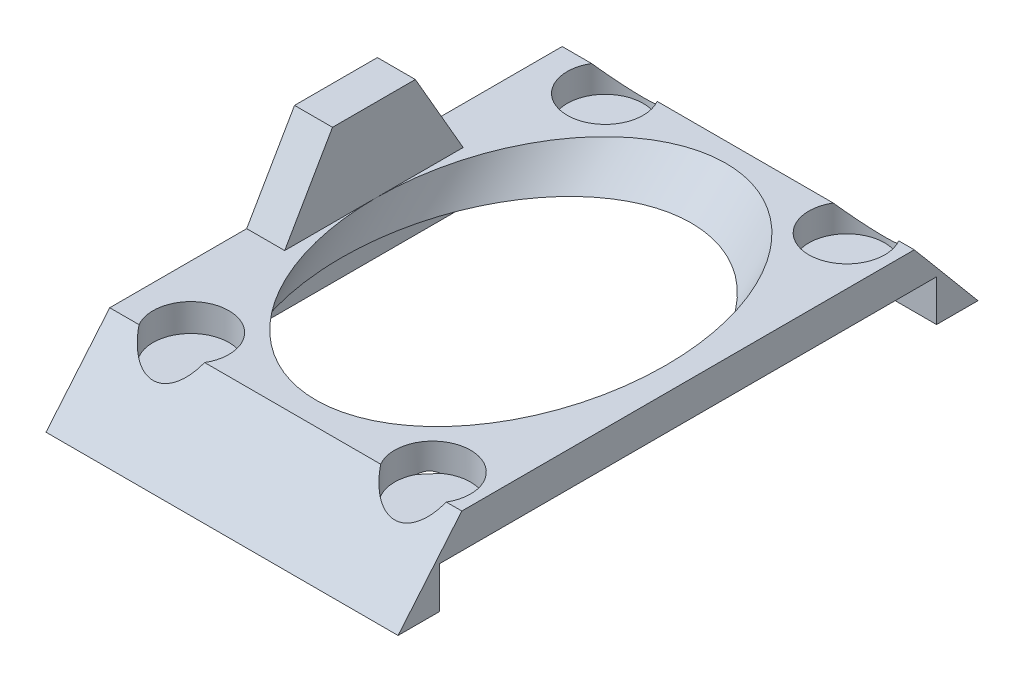
from build123d import *

# Parameters (mm, degrees)
SKETCH1_W                = 25.5
SKETCH1_H                = 42
BOSS_EXTRUDE1_DEPTH      = 5.5
SKETCH2_W                = 25
SKETCH2_H                = 36
CUT_EXTRUDE1_DEPTH       = 3
SKETCH3_R                = 10.5
CUT_EXTRUDE6_DEPTH       = 29
SKETCH6_R                = 2.75
CUT_EXTRUDE7_DEPTH       = 2
CUT_EXTRUDE8_DEPTH       = 13.5
CUT_EXTRUDE8_DEPTH_BACK  = 14
BOSS_EXTRUDE2_DEPTH      = 2.75
SKETCH9_R                = 2.5
CUT_EXTRUDE11_DEPTH      = 2.25
CUT_EXTRUDE12_DEPTH      = 13.5
CUT_EXTRUDE12_DEPTH_BACK = 14


with BuildPart() as part:
    # Sketch1 → Boss-Extrude1 (new body)
    with BuildSketch(Plane(origin=(0, 0, 0), x_dir=(1, 0, 0), z_dir=(0, 1, 0))):
        with Locations((-0.25, 0)):
            Rectangle(SKETCH1_W, SKETCH1_H)
    extrude(amount=BOSS_EXTRUDE1_DEPTH)

    # Sketch2 → Cut-Extrude1 (cut)
    with BuildSketch(Plane.XZ):
        with Locations((0.5, 0)):
            Rectangle(SKETCH2_W, SKETCH2_H)
    extrude(amount=-CUT_EXTRUDE1_DEPTH, mode=Mode.SUBTRACT)

    # Sketch3 → Cut-Extrude6 (cut)
    with BuildSketch(Plane(origin=(0, 13.25, -13.25), x_dir=(1, 0, 0), z_dir=(0, 0.707106781, -0.707106781))):
        with Locations((0.25, -3.789844892)):
            Circle(SKETCH3_R)
    extrude(amount=-CUT_EXTRUDE6_DEPTH, mode=Mode.SUBTRACT)

    # Sketch6 → Cut-Extrude7 (cut)
    with BuildSketch(Plane(origin=(0, 5.5, 0), x_dir=(1, 0, 0), z_dir=(0, 1, 0))):
        with Locations((-8.5, 15)):
            Circle(SKETCH6_R)
        with Locations((9, 15)):
            Circle(SKETCH6_R)
        with Locations((-8.5, -15)):
            Circle(SKETCH6_R)
        with Locations((9, -15)):
            Circle(SKETCH6_R)
    extrude(amount=-CUT_EXTRUDE7_DEPTH, mode=Mode.SUBTRACT)

    # Sketch7 → Cut-Extrude8 (cut, two sides)
    with BuildSketch(Plane(origin=(0, 0, 0), x_dir=(0, 0, -1), z_dir=(1, 0, 0))) as cut_extrude8_sk:
        Polygon((-21, 0), (-12.82380275, 9.744012446), (-21, 9.744012446), align=None)
    extrude(amount=CUT_EXTRUDE8_DEPTH, mode=Mode.SUBTRACT)
    extrude(cut_extrude8_sk.sketch, amount=-CUT_EXTRUDE8_DEPTH_BACK, mode=Mode.SUBTRACT)

    # Sketch8 → Boss-Extrude2 (add)
    with BuildSketch(Plane(origin=(-13, 0, 0), x_dir=(0, 0, -1), z_dir=(1, 0, 0))):
        Polygon((-3, 11.5), (3, 11.5), (6.464101615, 5.5), (-6.464101615, 5.5), align=None)
    extrude(amount=BOSS_EXTRUDE2_DEPTH)

    # Sketch9 → Cut-Extrude11 (cut)
    with BuildSketch(Plane(origin=(-13, 0, 0), x_dir=(0, 0, -1), z_dir=(1, 0, 0))):
        with Locations((0, 8.5)):
            Circle(SKETCH9_R)
    extrude(amount=CUT_EXTRUDE11_DEPTH, mode=Mode.SUBTRACT)

    # Sketch10 → Cut-Extrude12 (cut, two sides)
    with BuildSketch(Plane(origin=(0, 0, 0), x_dir=(0, 0, -1), z_dir=(1, 0, 0))) as cut_extrude12_sk:
        Polygon((21, 0), (15.965402213, 6), (21, 6), align=None)
    extrude(amount=CUT_EXTRUDE12_DEPTH, mode=Mode.SUBTRACT)
    extrude(cut_extrude12_sk.sketch, amount=-CUT_EXTRUDE12_DEPTH_BACK, mode=Mode.SUBTRACT)


solid = part.part
